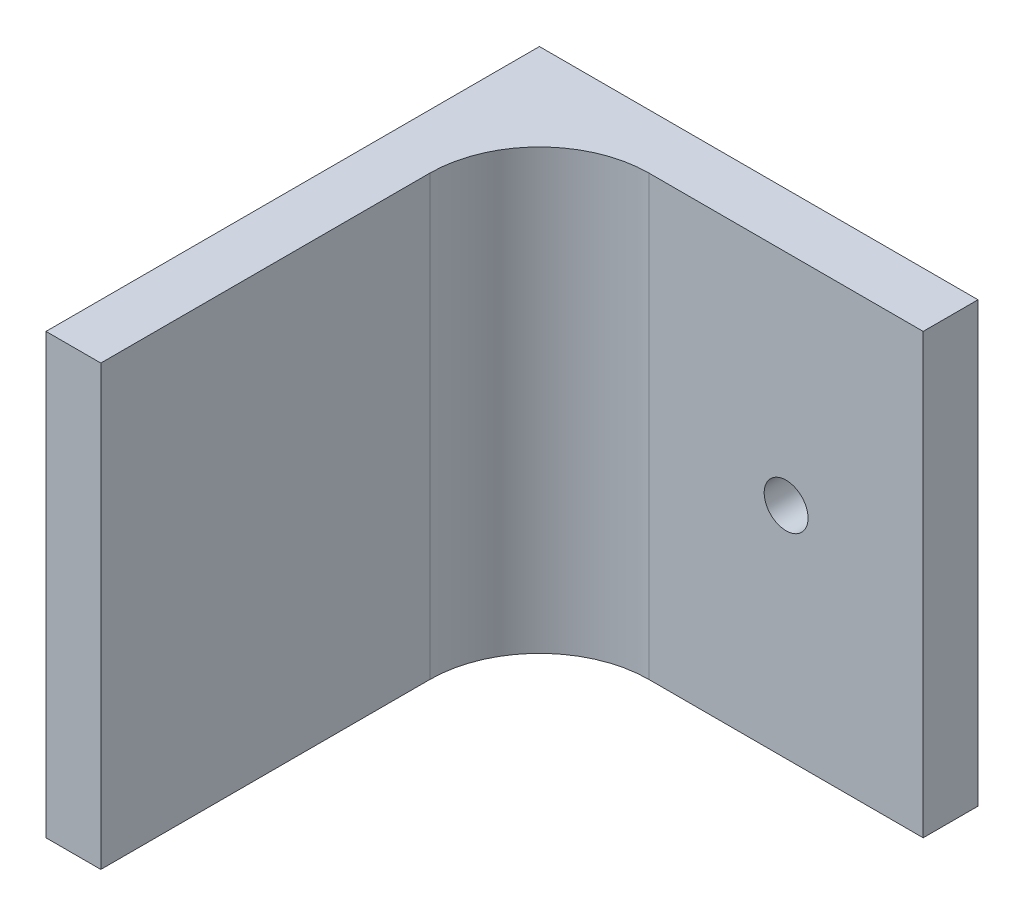
from build123d import *

# Parameters (mm, degrees)
SKETCH2_W           = 20
SKETCH2_H           = 20
BOSS_EXTRUDE1_DEPTH = 2.5
SKETCH3_W           = 2.5
SKETCH3_H           = 20
BOSS_EXTRUDE2_DEPTH = 22.5
FILLET1_R           = 5
SKETCH4_R           = 1
CUT_EXTRUDE1_DEPTH  = 22.5


with BuildPart() as part:
    # Sketch2 → Boss-Extrude1 (new body)
    with BuildSketch(Plane.XY):
        with Locations((77.998956535, 8.484810347)):
            Rectangle(SKETCH2_W, SKETCH2_H)
    extrude(amount=BOSS_EXTRUDE1_DEPTH)

    # Sketch3 → Boss-Extrude2 (add)
    with BuildSketch(Plane.XY):
        with Locations((69.248956535, 8.484810347)):
            Rectangle(SKETCH3_W, SKETCH3_H)
    extrude(amount=BOSS_EXTRUDE2_DEPTH)

    # Fillet1
    fillet1_edges = [part.edges().sort_by_distance(p)[0] for p in [
        (70.498956535, 8.484810347, 2.5),
    ]]
    fillet(fillet1_edges, radius=FILLET1_R)

    # Sketch4 → Cut-Extrude1 (cut)
    with BuildSketch(Plane.XY.offset(2.5)):
        with Locations((81.748956535, 8.484810347)):
            Circle(SKETCH4_R)
    extrude(amount=-CUT_EXTRUDE1_DEPTH, mode=Mode.SUBTRACT)


solid = part.part
